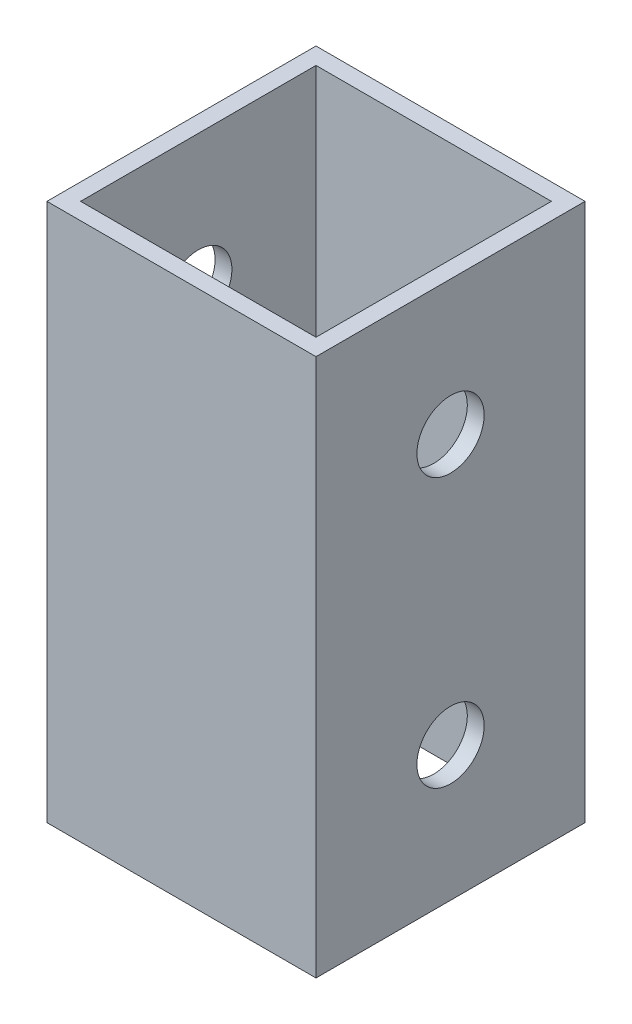
from build123d import *

# Parameters (mm, degrees)
SKETCH1_W           = 25.4
SKETCH1_H           = 25.4
SKETCH1_W_2         = 22.225
SKETCH1_H_2         = 22.225
BOSS_EXTRUDE1_DEPTH = 50.8
SKETCH2_R           = 3.175
CUT_EXTRUDE1_DEPTH  = 26.4


with BuildPart() as part:
    # Sketch1 → Boss-Extrude1 (new body)
    with BuildSketch(Plane(origin=(0, 0, 0), x_dir=(1, 0, 0), z_dir=(0, 1, 0))):
        Rectangle(SKETCH1_W, SKETCH1_H)
        Rectangle(SKETCH1_W_2, SKETCH1_H_2, mode=Mode.SUBTRACT)
    extrude(amount=BOSS_EXTRUDE1_DEPTH)

    # Sketch2 → Cut-Extrude1 (cut, through all)
    with BuildSketch(Plane(origin=(12.7, 0, 0), x_dir=(0, 0, -1), z_dir=(1, 0, 0))):
        with Locations((0, 38.1)):
            Circle(SKETCH2_R)
        with Locations((0, 12.7)):
            Circle(SKETCH2_R)
    extrude(amount=-CUT_EXTRUDE1_DEPTH, mode=Mode.SUBTRACT)


solid = part.part
